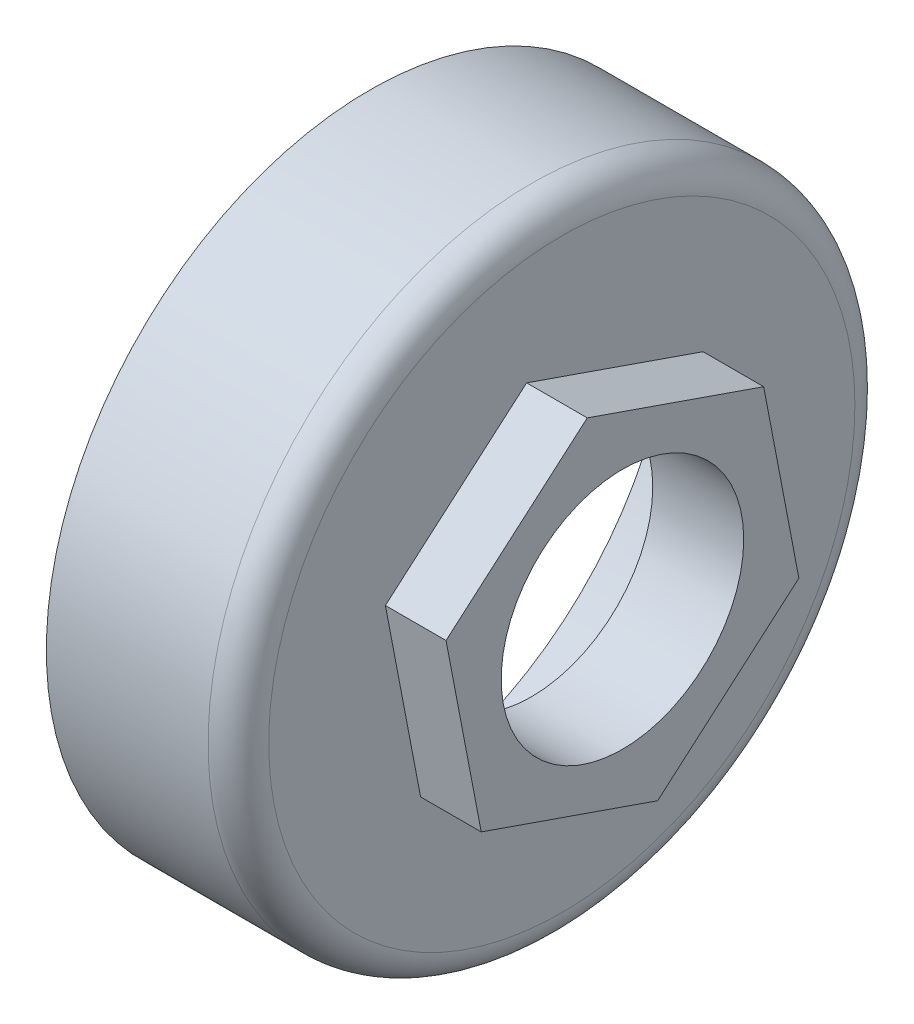
from build123d import *

# Parameters (mm, degrees)
SKETCH1_R           = 32
BOSS_EXTRUDE1_DEPTH = 19
SKETCH5_R           = 30
CUT_EXTRUDE1_DEPTH  = 16
FILLET1_R           = 3
BOSS_EXTRUDE2_DEPTH = 6
SKETCH7_R           = 12
CUT_EXTRUDE2_DEPTH  = 26


with BuildPart() as part:
    # Sketch1 → Boss-Extrude1 (new body)
    with BuildSketch(Plane(origin=(0, 0, 0), x_dir=(0, 0, -1), z_dir=(1, 0, 0))):
        Circle(SKETCH1_R)
    extrude(amount=BOSS_EXTRUDE1_DEPTH)

    # Sketch5 → Cut-Extrude1 (cut)
    with BuildSketch(Plane.ZY):
        Circle(SKETCH5_R)
    extrude(amount=-CUT_EXTRUDE1_DEPTH, mode=Mode.SUBTRACT)

    # Fillet1
    fillet1_edges = [part.edges().sort_by_distance(p)[0] for p in [
        (19, 0, 32),
    ]]
    fillet(fillet1_edges, radius=FILLET1_R)

    # Sketch6 → Boss-Extrude2 (add)
    with BuildSketch(Plane(origin=(19, 0, 0), x_dir=(0, 0, -1), z_dir=(1, 0, 0))):
        Polygon((-17.454071761, 6.057120794), (-13.972656361, -12.087109147), (3.481415399, -18.144229941), (17.454071761, -6.057120794), (13.972656361, 12.087109147), (-3.481415399, 18.144229941), align=None)
    extrude(amount=BOSS_EXTRUDE2_DEPTH)

    # Sketch7 → Cut-Extrude2 (cut, through all)
    with BuildSketch(Plane(origin=(25, 0, 0), x_dir=(0, 0, -1), z_dir=(1, 0, 0))):
        Circle(SKETCH7_R)
    extrude(amount=-CUT_EXTRUDE2_DEPTH, mode=Mode.SUBTRACT)


solid = part.part
